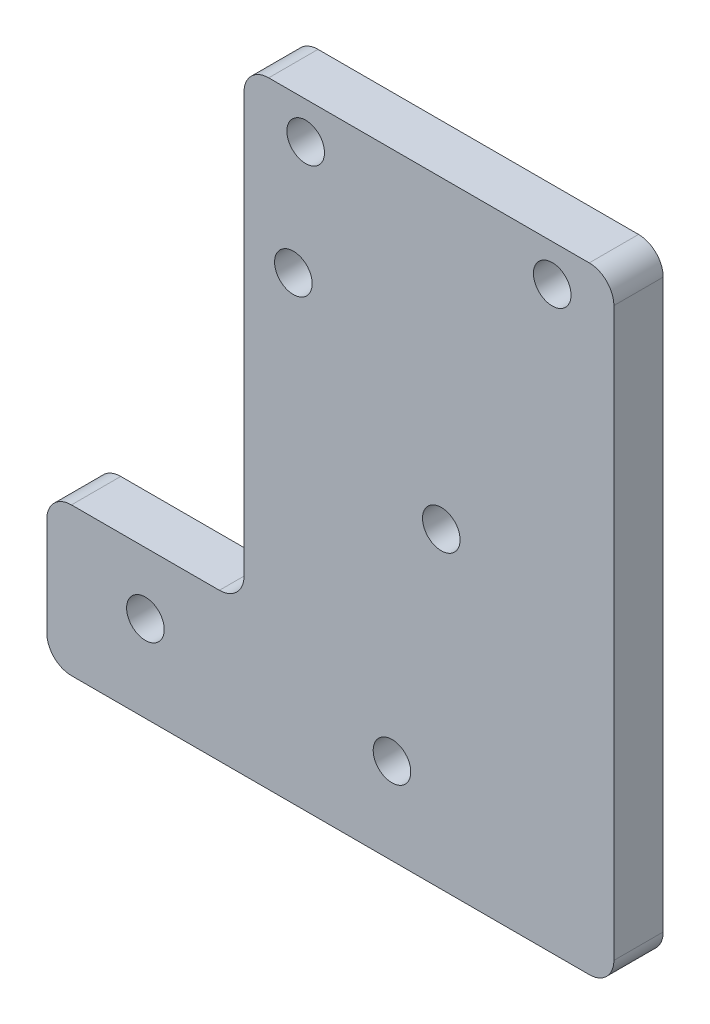
from build123d import *

# Parameters (mm, degrees)
SKETCH_2_W          = 30
SKETCH_2_H          = 30
EXTRUDE_1_DEPTH     = 2
SKETCH_3_W          = 30
SKETCH_3_H          = 20
EXTRUDE_2_DEPTH     = 4
SKETCH_6_R          = 1.525
CUT_EXTRUDE_1_DEPTH = 80
SKETCH_7_W          = 16
SKETCH_7_H          = 12
EXTRUDE_3_DEPTH     = 4
SKETCH_9_R          = 1.525
CUT_EXTRUDE_2_DEPTH = 4
FILLET_2_R          = 2


with BuildPart() as part:
    # 草图2 → 凸台-拉伸1 (new body, symmetric)
    with BuildSketch(Plane.XY):
        Rectangle(SKETCH_2_W, SKETCH_2_H)
    extrude(amount=EXTRUDE_1_DEPTH, both=True)

    # 草图3 → 凸台-拉伸2 (add)
    with BuildSketch(Plane.XY.offset(2)):
        with Locations((0, -25)):
            Rectangle(SKETCH_3_W, SKETCH_3_H)
    extrude(amount=-EXTRUDE_2_DEPTH)

    # 草图6 → 切除-拉伸1 (cut)
    with BuildSketch(Plane.XY.offset(2)):
        with Locations((1, -9.7)):
            Circle(SKETCH_6_R)
        with Locations((-11, 2.3)):
            Circle(SKETCH_6_R)
        with Locations((-10, 12)):
            Circle(SKETCH_6_R)
        with Locations((10, 12)):
            Circle(SKETCH_6_R)
    extrude(amount=-CUT_EXTRUDE_1_DEPTH, mode=Mode.SUBTRACT)

    # 草图7 → 凸台-拉伸3 (add)
    with BuildSketch(Plane.XY.offset(2)):
        with Locations((-23, -29)):
            Rectangle(SKETCH_7_W, SKETCH_7_H)
    extrude(amount=-EXTRUDE_3_DEPTH)

    # 草图9 → 切除-拉伸2 (cut)
    with BuildSketch(Plane(origin=(0, 0, -2), x_dir=(-1, 0, 0), z_dir=(0, 0, -1))):
        with Locations((3, -28)):
            Circle(SKETCH_9_R)
        with Locations((23, -28)):
            Circle(SKETCH_9_R)
    extrude(amount=-CUT_EXTRUDE_2_DEPTH, mode=Mode.SUBTRACT)

    # 圆角2
    fillet_2_edges = [part.edges().sort_by_distance(p)[0] for p in [
        (15, -35, 0),
        (-31, -23, 0),
        (-31, -35, 0),
        (-15, -23, 0),
        (-15, 15, 0),
        (15, 15, 0),
    ]]
    fillet(fillet_2_edges, radius=FILLET_2_R)


solid = part.part
